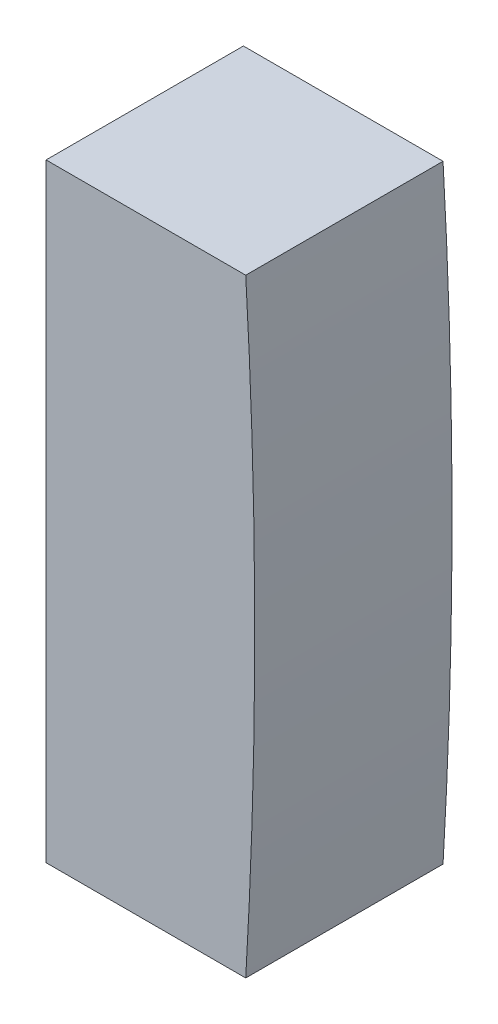
from build123d import *

# Parameters (mm, degrees)
EXTRUDE1_DEPTH = 2.715


with BuildPart() as part:
    # Sketch1 → Extrude1 (new body, symmetric)
    with BuildSketch(Plane.XY):
        with BuildLine():
            Line((141.752810819, 8.375), (136.25860116, 8.375))
            Line((136.25860116, 8.375), (136.25860116, -8.375))
            Line((136.25860116, -8.375), (141.752810819, -8.375))
            ThreePointArc((141.752810819, -8.375), (142, 0), (141.752810819, 8.375))
        make_face()
    extrude(amount=EXTRUDE1_DEPTH, both=True)


solid = part.part
